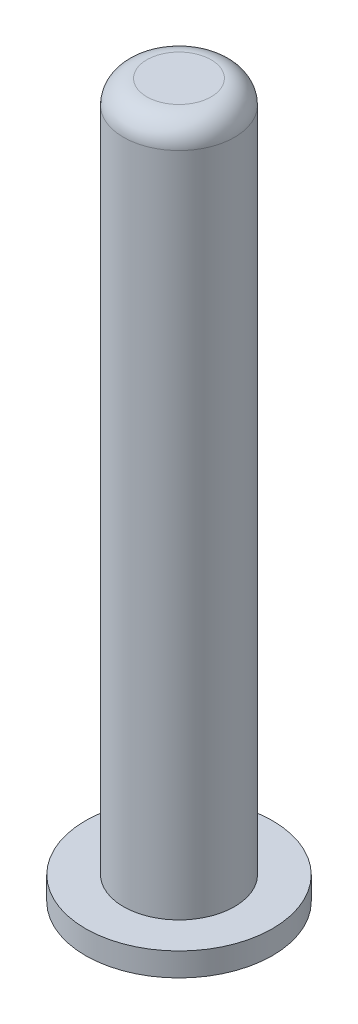
from build123d import *

# Parameters (mm, degrees)
SKETCH1_R           = 4.75
BOSS_EXTRUDE1_DEPTH = 59
SKETCH2_R           = 8
BOSS_EXTRUDE2_DEPTH = 2
FILLET1_R           = 2


with BuildPart() as part:
    # Sketch1 → Boss-Extrude1 (new body)
    with BuildSketch(Plane(origin=(0, 0, 0), x_dir=(1, 0, 0), z_dir=(0, 1, 0))):
        Circle(SKETCH1_R)
    extrude(amount=BOSS_EXTRUDE1_DEPTH)

    # Sketch2 → Boss-Extrude2 (add)
    with BuildSketch(Plane(origin=(0, 0, 0), x_dir=(-1, 0, 0), z_dir=(0, -1, 0))):
        Circle(SKETCH2_R)
    extrude(amount=BOSS_EXTRUDE2_DEPTH)

    # Fillet1
    fillet1_edges = [part.edges().sort_by_distance(p)[0] for p in [
        (-4.75, 59, 0),
    ]]
    fillet(fillet1_edges, radius=FILLET1_R)


solid = part.part
